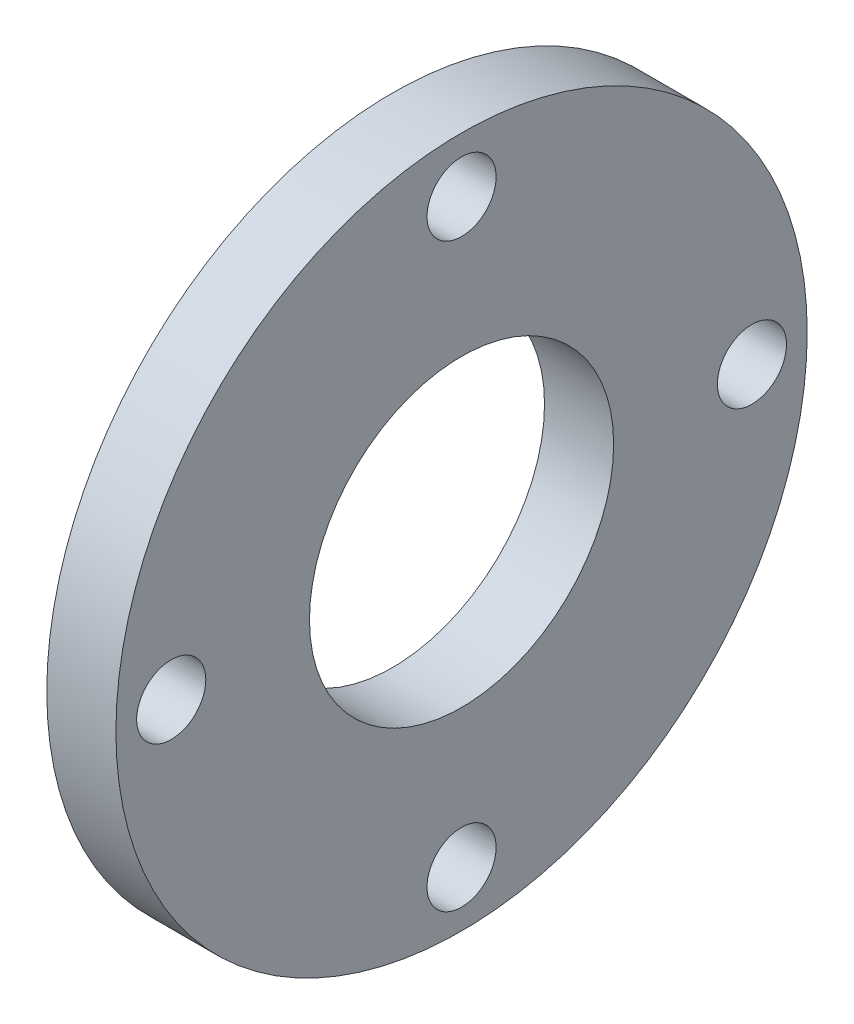
from build123d import *

# Parameters (mm, degrees)
CROQUIS1_R              = 25
CROQUIS1_R_2            = 11
SALIENTE_EXTRUIR1_DEPTH = 5
CROQUIS2_R              = 2.5
CORTAR_EXTRUIR1_DEPTH   = 10


with BuildPart() as part:
    # Croquis1 → Saliente-Extruir1 (new body)
    with BuildSketch(Plane(origin=(0, 0, 0), x_dir=(0, 0, -1), z_dir=(1, 0, 0))):
        Circle(CROQUIS1_R)
        Circle(CROQUIS1_R_2, mode=Mode.SUBTRACT)
    extrude(amount=SALIENTE_EXTRUIR1_DEPTH)

    # Croquis2 → Cortar-Extruir1 (cut)
    with BuildSketch(Plane(origin=(5, 0, 0), x_dir=(0, 0, -1), z_dir=(1, 0, 0))):
        with Locations((0, 21)):
            Circle(CROQUIS2_R)
        with Locations((21, 0)):
            Circle(CROQUIS2_R)
        with Locations((0, -21)):
            Circle(CROQUIS2_R)
        with Locations((-21, 0)):
            Circle(CROQUIS2_R)
    extrude(amount=-CORTAR_EXTRUIR1_DEPTH, mode=Mode.SUBTRACT)


solid = part.part
